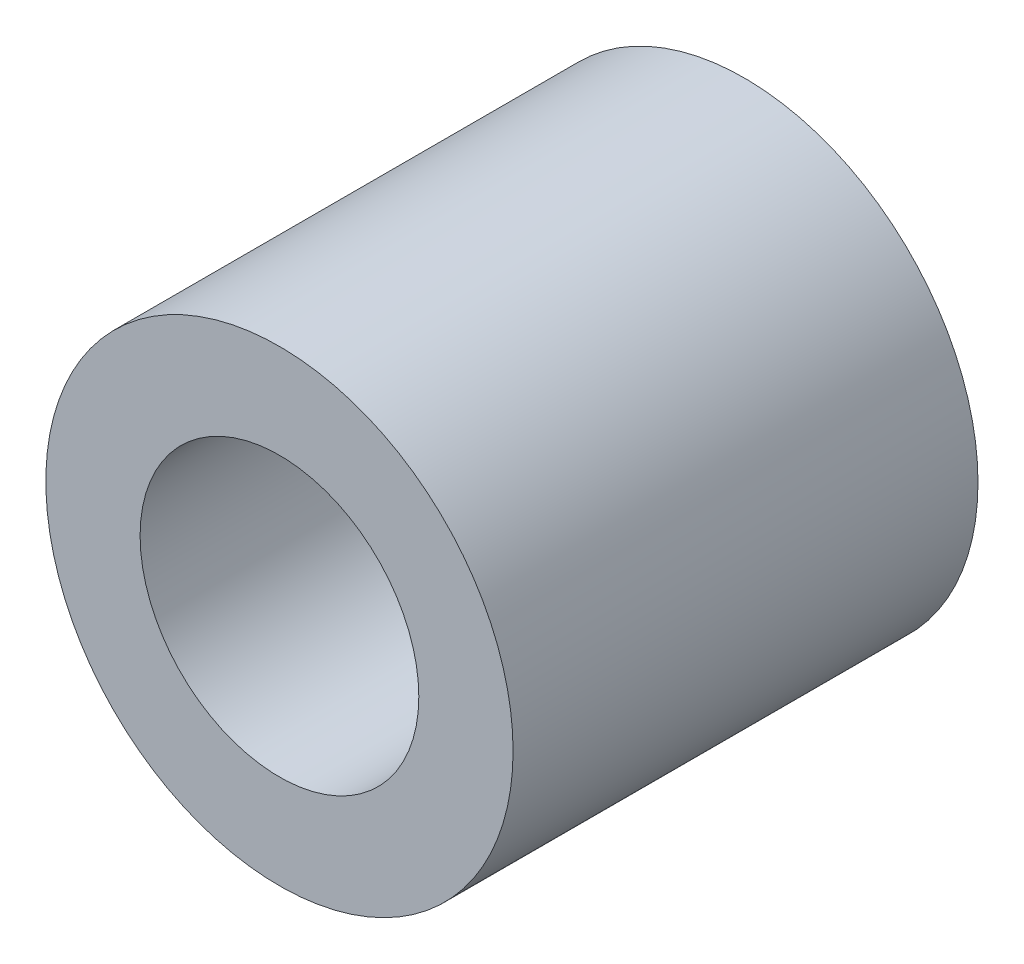
from build123d import *

# Parameters (mm, degrees)
SKETCH1_R           = 10.05
SKETCH1_R_2         = 5.995
BOSS_EXTRUDE1_DEPTH = 20


with BuildPart() as part:
    # Sketch1 → Boss-Extrude1 (new body)
    with BuildSketch(Plane.XY):
        Circle(SKETCH1_R)
        Circle(SKETCH1_R_2, mode=Mode.SUBTRACT)
    extrude(amount=BOSS_EXTRUDE1_DEPTH)


solid = part.part
